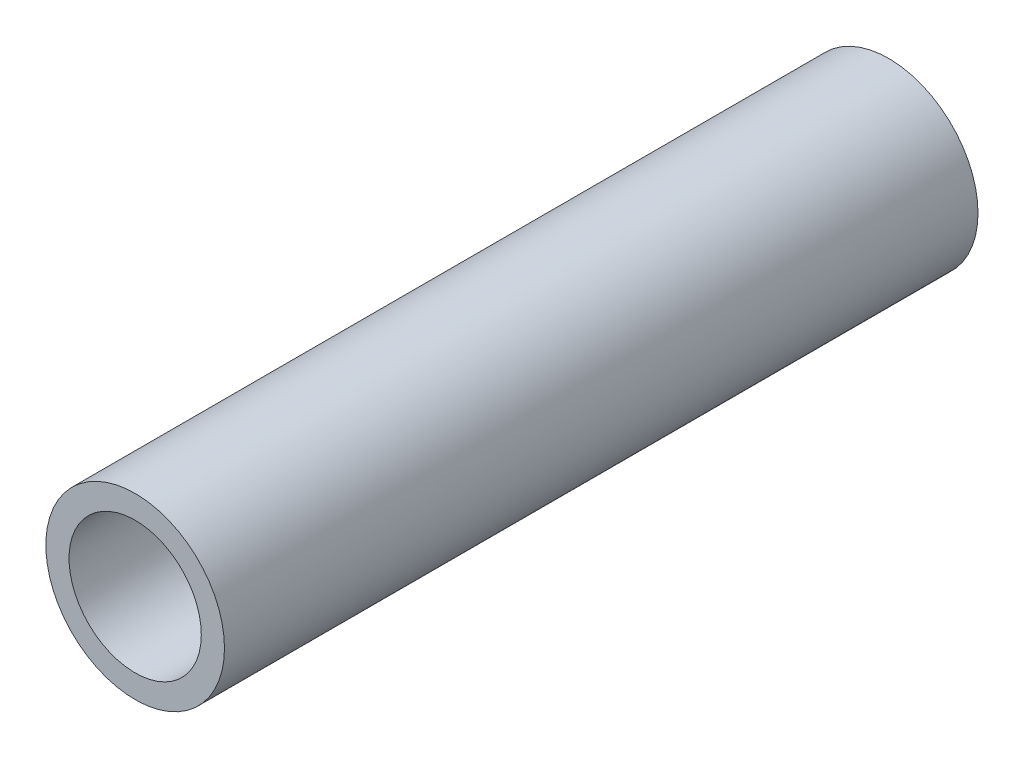
from build123d import *

# Parameters (mm, degrees)
SKETCH1_R           = 10.668
SKETCH1_R_2         = 7.8994
EXTRUDE_THIN1_DEPTH = 45


with BuildPart() as part:
    # Sketch1 → Extrude-Thin1 (new body, symmetric)
    with BuildSketch(Plane.XY):
        Circle(SKETCH1_R)
        Circle(SKETCH1_R_2, mode=Mode.SUBTRACT)
    extrude(amount=EXTRUDE_THIN1_DEPTH, both=True)


solid = part.part
